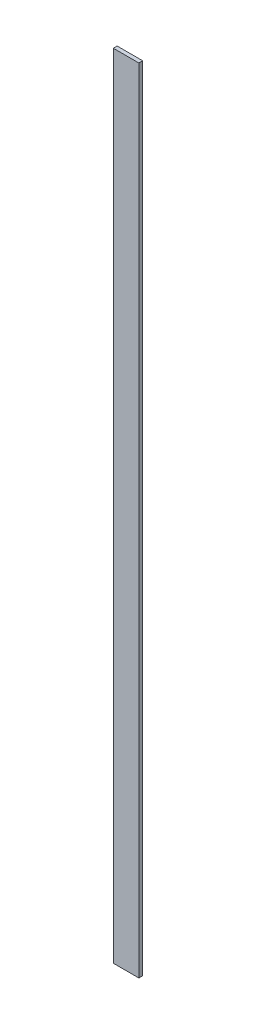
from build123d import *

# Parameters (mm, degrees)
SKETCH1_W           = 20
SKETCH1_H           = 620
BOSS_EXTRUDE1_DEPTH = 3


with BuildPart() as part:
    # Sketch1 → Boss-Extrude1 (new body)
    with BuildSketch(Plane.XY.offset(-52.811189353)):
        with Locations((-304.293069475, 410)):
            Rectangle(SKETCH1_W, SKETCH1_H)
    extrude(amount=BOSS_EXTRUDE1_DEPTH)


solid = part.part
